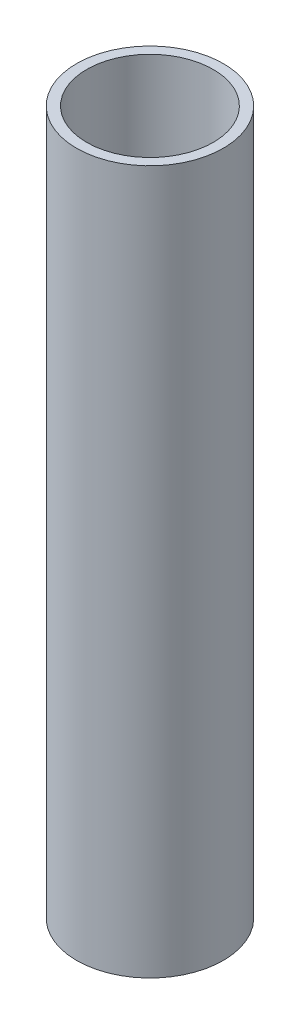
from build123d import *

# Parameters (mm, degrees)
SKETCH2_R           = 58.293
SKETCH2_R_2         = 50.2539
BOSS_EXTRUDE1_DEPTH = 558.8


with BuildPart() as part:
    # Sketch2 → Boss-Extrude1 (new body)
    with BuildSketch(Plane(origin=(0, 0, 0), x_dir=(1, 0, 0), z_dir=(0, 1, 0))):
        Circle(SKETCH2_R)
        Circle(SKETCH2_R_2, mode=Mode.SUBTRACT)
    extrude(amount=BOSS_EXTRUDE1_DEPTH)


solid = part.part
